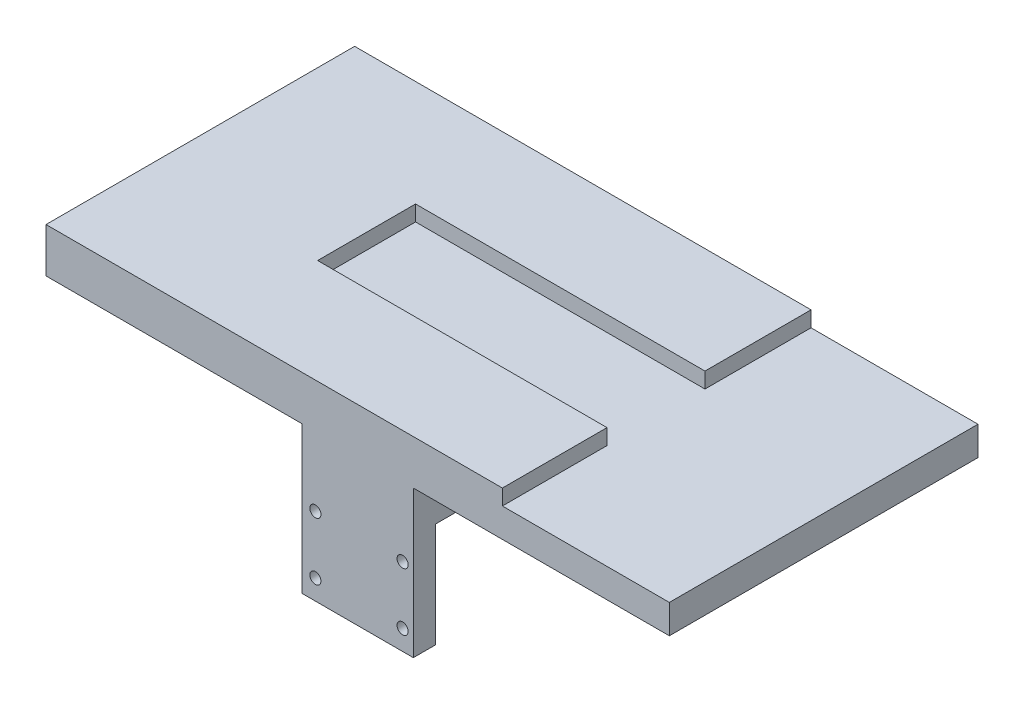
from build123d import *

# Parameters (mm, degrees)
SKETCH1_W           = 25
SKETCH1_H           = 38
BOSS_EXTRUDE1_DEPTH = 12
SKETCH3_W           = 25
SKETCH3_H           = 12
BOSS_EXTRUDE2_DEPTH = 5.5
SKETCH5_W           = 25
SKETCH5_H           = 5
BOSS_EXTRUDE3_DEPTH = 21
SKETCH6_R           = 1.25
CUT_EXTRUDE1_DEPTH  = 10
SKETCH7_W           = 75
SKETCH7_H           = 49
BOSS_EXTRUDE4_DEPTH = 10
SKETCH8_W           = 65
SKETCH8_H           = 12
CUT_EXTRUDE2_DEPTH  = 3.5
SKETCH11_W          = 25
SKETCH11_H          = 39
CUT_EXTRUDE4_DEPTH  = 2.5
SKETCH12_W          = 75
SKETCH12_H          = 10
BOSS_EXTRUDE6_DEPTH = 20.32
SKETCH15_W          = 69.32
SKETCH15_H          = 10
BOSS_EXTRUDE7_DEPTH = 32.5
SKETCH16_W          = 69.32
SKETCH16_H          = 10
BOSS_EXTRUDE8_DEPTH = 32.5
SKETCH19_W          = 12
SKETCH19_H          = 3.5
CUT_EXTRUDE6_DEPTH  = 38.5
SKETCH23_W          = 102.5
SKETCH23_H          = 3.5
CUT_EXTRUDE7_DEPTH  = 5
SKETCH24_W          = 102.5
SKETCH24_H          = 3.5
CUT_EXTRUDE8_DEPTH  = 5
SKETCH25_W          = 37.5
SKETCH25_H          = 69.32
CUT_EXTRUDE9_DEPTH  = 3.5


with BuildPart() as part:
    # Sketch1 → Boss-Extrude1 (new body)
    with BuildSketch(Plane(origin=(0, 0, 0), x_dir=(1, 0, 0), z_dir=(0, 1, 0))):
        with Locations((12.5, 19)):
            Rectangle(SKETCH1_W, SKETCH1_H)
    extrude(amount=BOSS_EXTRUDE1_DEPTH)

    # Sketch3 → Boss-Extrude2 (add)
    with BuildSketch(Plane.XY):
        with Locations((12.5, 6)):
            Rectangle(SKETCH3_W, SKETCH3_H)
    boss_extrude2 = extrude(amount=BOSS_EXTRUDE2_DEPTH)

    # Sketch5 → Boss-Extrude3 (add)
    with BuildSketch(Plane.XZ):
        with Locations((12.5, 3)):
            Rectangle(SKETCH5_W, SKETCH5_H)
    boss_extrude3 = extrude(amount=BOSS_EXTRUDE3_DEPTH)

    # Sketch6 → Cut-Extrude1 (cut)
    with BuildSketch(Plane.XY.offset(5.5)):
        with Locations((3, -16.5)):
            Circle(SKETCH6_R)
        with Locations((22.59, -16.5)):
            Circle(SKETCH6_R)
        with Locations((22.59, -3.53)):
            Circle(SKETCH6_R)
        with Locations((3, -3.53)):
            Circle(SKETCH6_R)
    cut_extrude1 = extrude(amount=-CUT_EXTRUDE1_DEPTH, mode=Mode.SUBTRACT)

    # Mirror1: Boss-Extrude2, Boss-Extrude3, Cut-Extrude1 across plane
    add(boss_extrude2.mirror(Plane.XY.offset(-19)))
    add(boss_extrude3.mirror(Plane.XY.offset(-19)))
    add(cut_extrude1.mirror(Plane.XY.offset(-19)), mode=Mode.SUBTRACT)

    # Sketch7 → Boss-Extrude4 (add)
    with BuildSketch(Plane(origin=(0, 12, 0), x_dir=(1, 0, 0), z_dir=(0, 1, 0))):
        with Locations((12.5, 19)):
            Rectangle(SKETCH7_W, SKETCH7_H)
    extrude(amount=BOSS_EXTRUDE4_DEPTH)

    # Sketch8 → Cut-Extrude2 (cut)
    with BuildSketch(Plane(origin=(0, 22, 0), x_dir=(1, 0, 0), z_dir=(0, 1, 0))):
        with Locations((12.5, 29)):
            Rectangle(SKETCH8_W, SKETCH8_H)
    extrude(amount=-CUT_EXTRUDE2_DEPTH, mode=Mode.SUBTRACT)

    # Sketch11 → Cut-Extrude4 (cut)
    with BuildSketch(Plane.XZ):
        with Locations((12.5, -19)):
            Rectangle(SKETCH11_W, SKETCH11_H)
    extrude(amount=-CUT_EXTRUDE4_DEPTH, mode=Mode.SUBTRACT)

    # Sketch12 → Boss-Extrude6 (add)
    with BuildSketch(Plane(origin=(0, 0, -43.5), x_dir=(-1, 0, 0), z_dir=(0, 0, -1))):
        with Locations((-12.5, 17)):
            Rectangle(SKETCH12_W, SKETCH12_H)
    extrude(amount=BOSS_EXTRUDE6_DEPTH)

    # Sketch15 → Boss-Extrude7 (add)
    with BuildSketch(Plane(origin=(50, 0, 0), x_dir=(0, 0, -1), z_dir=(1, 0, 0))):
        with Locations((29.16, 17)):
            Rectangle(SKETCH15_W, SKETCH15_H)
    extrude(amount=BOSS_EXTRUDE7_DEPTH)

    # Sketch16 → Boss-Extrude8 (add)
    with BuildSketch(Plane.ZY.offset(25)):
        with Locations((-29.16, 17)):
            Rectangle(SKETCH16_W, SKETCH16_H)
    extrude(amount=BOSS_EXTRUDE8_DEPTH)

    # Sketch19 → Cut-Extrude6 (cut, through all)
    with BuildSketch(Plane.ZY.offset(-45)):
        with Locations((-29, 20.25)):
            Rectangle(SKETCH19_W, SKETCH19_H)
    extrude(amount=-CUT_EXTRUDE6_DEPTH, mode=Mode.SUBTRACT)

    # Sketch23 → Cut-Extrude7 (cut)
    with BuildSketch(Plane.XY.offset(-35)):
        with Locations((31.25, 20.25)):
            Rectangle(SKETCH23_W, SKETCH23_H)
    extrude(amount=-CUT_EXTRUDE7_DEPTH, mode=Mode.SUBTRACT)

    # Sketch24 → Cut-Extrude8 (cut)
    with BuildSketch(Plane(origin=(0, 0, -23), x_dir=(-1, 0, 0), z_dir=(0, 0, -1))):
        with Locations((-31.25, 20.25)):
            Rectangle(SKETCH24_W, SKETCH24_H)
    extrude(amount=-CUT_EXTRUDE8_DEPTH, mode=Mode.SUBTRACT)

    # Sketch25 → Cut-Extrude9 (cut)
    with BuildSketch(Plane(origin=(0, 22, 0), x_dir=(1, 0, 0), z_dir=(0, 1, 0))):
        with Locations((63.75, 29.16)):
            Rectangle(SKETCH25_W, SKETCH25_H)
    extrude(amount=-CUT_EXTRUDE9_DEPTH, mode=Mode.SUBTRACT)


solid = part.part
